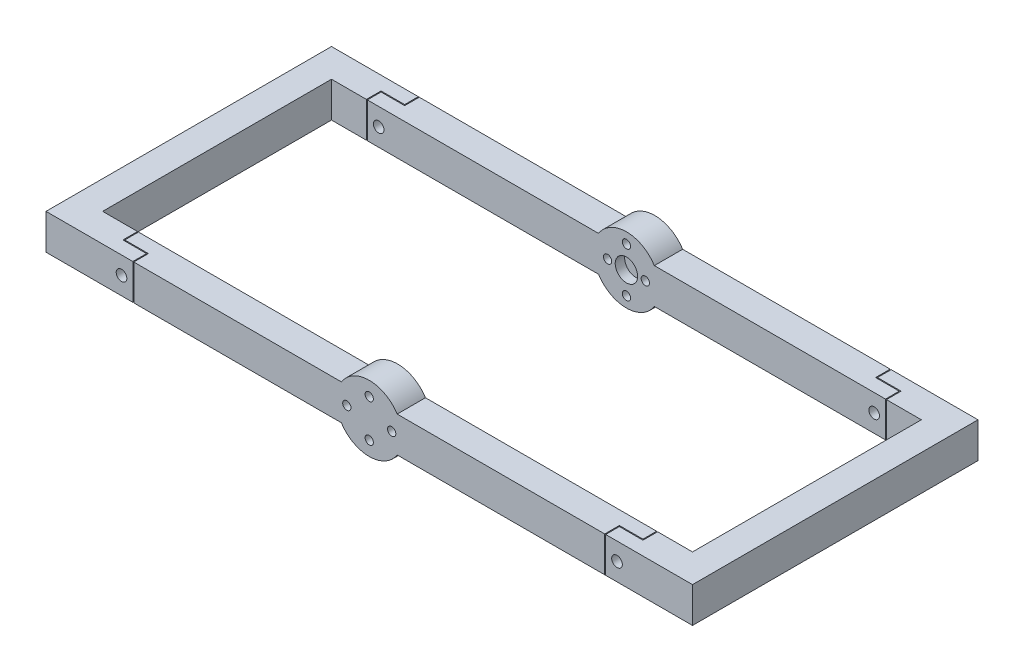
from build123d import *

# Parameters (mm, degrees)
SKETCH2_R           = 14
BOSS_EXTRUDE1_DEPTH = 12
SKETCH10_W          = 12
SKETCH10_H          = 15
BOSS_EXTRUDE5_DEPTH = 137
SKETCH11_W          = 12
SKETCH11_H          = 15
BOSS_EXTRUDE6_DEPTH = 97
SKETCH12_W          = 12
SKETCH12_H          = 15
BOSS_EXTRUDE7_DEPTH = 137
SKETCH13_R          = 14
BOSS_EXTRUDE8_DEPTH = 12
SKETCH4_R           = 4.75
CUT_EXTRUDE2_DEPTH  = 4
SKETCH3_R           = 1.75
CUT_EXTRUDE1_DEPTH  = 13
SKETCH14_R          = 4.75
CUT_EXTRUDE3_DEPTH  = 4
SKETCH15_R          = 1.75
CUT_EXTRUDE4_DEPTH  = 13
CUT_EXTRUDE5_DEPTH  = 22.5
SKETCH17_R          = 2.25
CUT_EXTRUDE6_DEPTH  = 122


with BuildPart() as part:
    # Sketch2 → Boss-Extrude1 (new body)
    with BuildSketch(Plane(origin=(0, 0, 12), x_dir=(-1, 0, 0), z_dir=(0, 0, -1))):
        Circle(SKETCH2_R)
    extrude(amount=BOSS_EXTRUDE1_DEPTH)

    # Sketch10 → Boss-Extrude5 (add)
    with BuildSketch(Plane(origin=(0, 0, 0), x_dir=(0, 0, -1), z_dir=(1, 0, 0))):
        with Locations((-6, 0)):
            Rectangle(SKETCH10_W, SKETCH10_H)
    boss_extrude5 = extrude(amount=BOSS_EXTRUDE5_DEPTH)

    # Sketch11 → Boss-Extrude6 (add)
    with BuildSketch(Plane.XY.offset(12)):
        with Locations((131, 0)):
            Rectangle(SKETCH11_W, SKETCH11_H)
    boss_extrude6 = extrude(amount=BOSS_EXTRUDE6_DEPTH)

    # Sketch12 → Boss-Extrude7 (add)
    with BuildSketch(Plane(origin=(137, 0, 0), x_dir=(0, 0, -1), z_dir=(1, 0, 0))):
        with Locations((-115, 0)):
            Rectangle(SKETCH12_W, SKETCH12_H)
    boss_extrude7 = extrude(amount=-BOSS_EXTRUDE7_DEPTH)

    # Sketch13 → Boss-Extrude8 (add)
    with BuildSketch(Plane.XY.offset(109)):
        Circle(SKETCH13_R)
    extrude(amount=BOSS_EXTRUDE8_DEPTH)

    # Mirror6: Boss-Extrude5, Boss-Extrude6, Boss-Extrude7 across plane
    add(boss_extrude5.mirror(Plane(origin=(0, 0, 0), x_dir=(0, 0, 1), z_dir=(1, 0, 0))))
    add(boss_extrude6.mirror(Plane(origin=(0, 0, 0), x_dir=(0, 0, 1), z_dir=(1, 0, 0))))
    add(boss_extrude7.mirror(Plane(origin=(0, 0, 0), x_dir=(0, 0, 1), z_dir=(1, 0, 0))))

    # Sketch4 → Cut-Extrude2 (cut)
    with BuildSketch(Plane.XY.offset(12)):
        Circle(SKETCH4_R)
    extrude(amount=-CUT_EXTRUDE2_DEPTH, mode=Mode.SUBTRACT)

    # Sketch3 → Cut-Extrude1 (cut, through all)
    with BuildSketch(Plane.XY.offset(12)):
        with Locations((8, 0)):
            Circle(SKETCH3_R)
        with Locations((0, -9.5)):
            Circle(SKETCH3_R)
        with Locations((-8, 0)):
            Circle(SKETCH3_R)
        with Locations((0, 9.5)):
            Circle(SKETCH3_R)
    extrude(amount=-CUT_EXTRUDE1_DEPTH, mode=Mode.SUBTRACT)

    # Sketch14 → Cut-Extrude3 (cut)
    with BuildSketch(Plane(origin=(0, 0, 109), x_dir=(-1, 0, 0), z_dir=(0, 0, -1))):
        Circle(SKETCH14_R)
    extrude(amount=-CUT_EXTRUDE3_DEPTH, mode=Mode.SUBTRACT)

    # Sketch15 → Cut-Extrude4 (cut, through all)
    with BuildSketch(Plane(origin=(0, 0, 109), x_dir=(-1, 0, 0), z_dir=(0, 0, -1))):
        with Locations((-9.5, 0)):
            Circle(SKETCH15_R)
        with Locations((0, 8)):
            Circle(SKETCH15_R)
        with Locations((9.5, 0)):
            Circle(SKETCH15_R)
        with Locations((0, -8)):
            Circle(SKETCH15_R)
    extrude(amount=-CUT_EXTRUDE4_DEPTH, mode=Mode.SUBTRACT)

    # Sketch16 → Cut-Extrude5 (cut, through all)
    with BuildSketch(Plane(origin=(0, 7.5, 0), x_dir=(1, 0, 0), z_dir=(0, 1, 0))):
        Polygon((99.8, 0), (99.8, -6.2), (109.8, -6.2), (109.8, -12), (110.2, -12), (110.2, -5.8), (100.2, -5.8), (100.2, 0), align=None)
        Polygon((109.8, -109), (110.2, -109), (110.2, -115.2), (100.2, -115.2), (100.2, -121), (99.8, -121), (99.8, -114.8), (109.8, -114.8), align=None)
        Polygon((-99.8, -121), (-100.2, -121), (-100.2, -115.2), (-110.2, -115.2), (-110.2, -109), (-109.8, -109), (-109.8, -114.8), (-99.8, -114.8), align=None)
        Polygon((-109.8, -12), (-110.2, -12), (-110.2, -5.8), (-100.2, -5.8), (-100.2, 0), (-99.8, 0), (-99.8, -6.2), (-109.8, -6.2), align=None)
    extrude(amount=-CUT_EXTRUDE5_DEPTH, mode=Mode.SUBTRACT)

    # Sketch17 → Cut-Extrude6 (cut, through all)
    with BuildSketch(Plane(origin=(0, 0, 0), x_dir=(-1, 0, 0), z_dir=(0, 0, -1))):
        with Locations((-105, 0)):
            Circle(SKETCH17_R)
    cut_extrude6 = extrude(amount=-CUT_EXTRUDE6_DEPTH, mode=Mode.SUBTRACT)

    # Mirror7: Cut-Extrude6 across plane
    add(cut_extrude6.mirror(Plane(origin=(0, 0, 0), x_dir=(0, 0, 1), z_dir=(1, 0, 0))), mode=Mode.SUBTRACT)


solid = part.part
